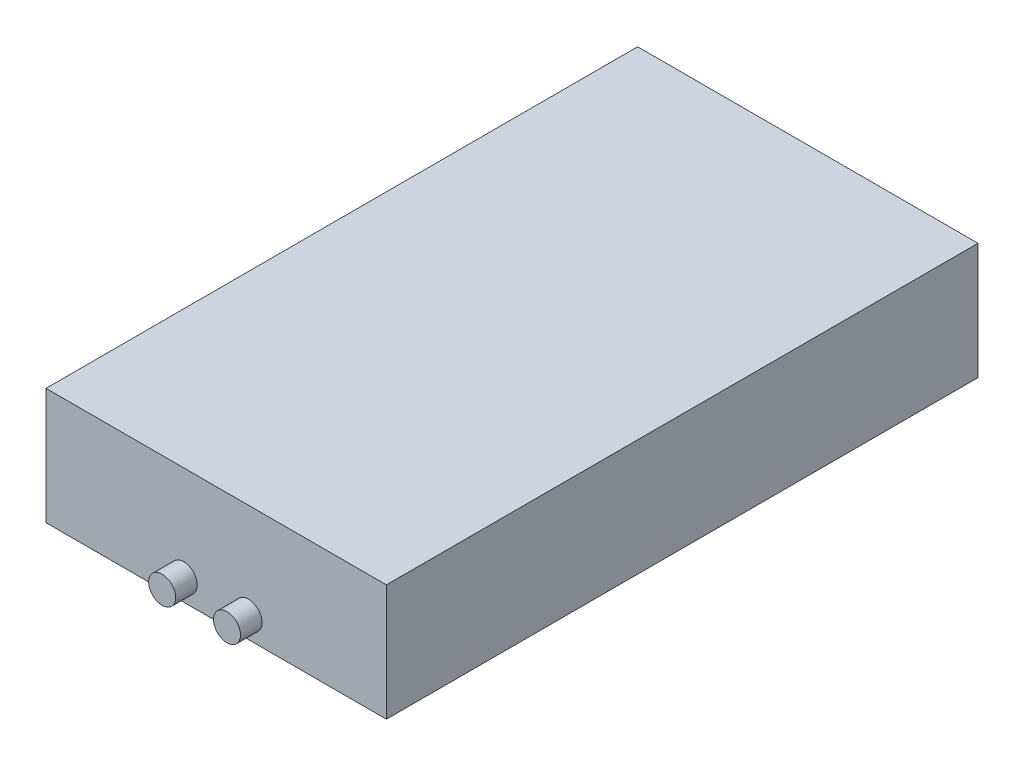
from build123d import *

# Parameters (mm, degrees)
SKETCH_1_W             = 63
SKETCH_1_H             = 21.54
EXTRUDE_1_DEPTH        = 109.5
HOLE_WIZARD_M2_1_D     = 1.6
HOLE_WIZARD_M2_1_DEPTH = 5.2
HOLE_WIZARD_M2_1_TIP   = 0.480688495
SKETCH_4_R             = 2.5
EXTRUDE_2_DEPTH        = 4
SKETCH_5_R             = 7.414302321
SKETCH_5_R_2           = 4.881421022
CUT_EXTRUDE_1_DEPTH    = 2


with BuildPart() as part:
    # 草图1 → 凸台-拉伸1 (new body)
    with BuildSketch(Plane.XY):
        Rectangle(SKETCH_1_W, SKETCH_1_H)
    extrude(amount=EXTRUDE_1_DEPTH)

    # M2 螺纹孔1
    with Locations(Plane(origin=(0, -10.77, 0), x_dir=(-1, 0, 0), z_dir=(0, -1, 0))):
        with Locations((7, -105.2), (-7, -105.2), (-22.309756999, -30.762521908), (22.309756999, -30.762521908)):
            Hole(HOLE_WIZARD_M2_1_D / 2, depth=HOLE_WIZARD_M2_1_DEPTH)
            with Locations((0, 0, -(HOLE_WIZARD_M2_1_DEPTH + HOLE_WIZARD_M2_1_TIP / 2))):  # 118° drill point
                Cone(0, HOLE_WIZARD_M2_1_D / 2, HOLE_WIZARD_M2_1_TIP, mode=Mode.SUBTRACT)

    # 草图4 → 凸台-拉伸2 (add)
    with BuildSketch(Plane.XY.offset(109.5)):
        with Locations((-6, -6.77)):
            Circle(SKETCH_4_R)
        with Locations((6, -6.77)):
            Circle(SKETCH_4_R)
    extrude(amount=EXTRUDE_2_DEPTH)

    # 草图5 → 切除-拉伸1 (cut)
    with BuildSketch(Plane(origin=(0, 0, 0), x_dir=(-1, 0, 0), z_dir=(0, 0, -1))):
        Circle(SKETCH_5_R)
        Circle(SKETCH_5_R_2, mode=Mode.SUBTRACT)
    extrude(amount=-CUT_EXTRUDE_1_DEPTH, mode=Mode.SUBTRACT)


solid = part.part
